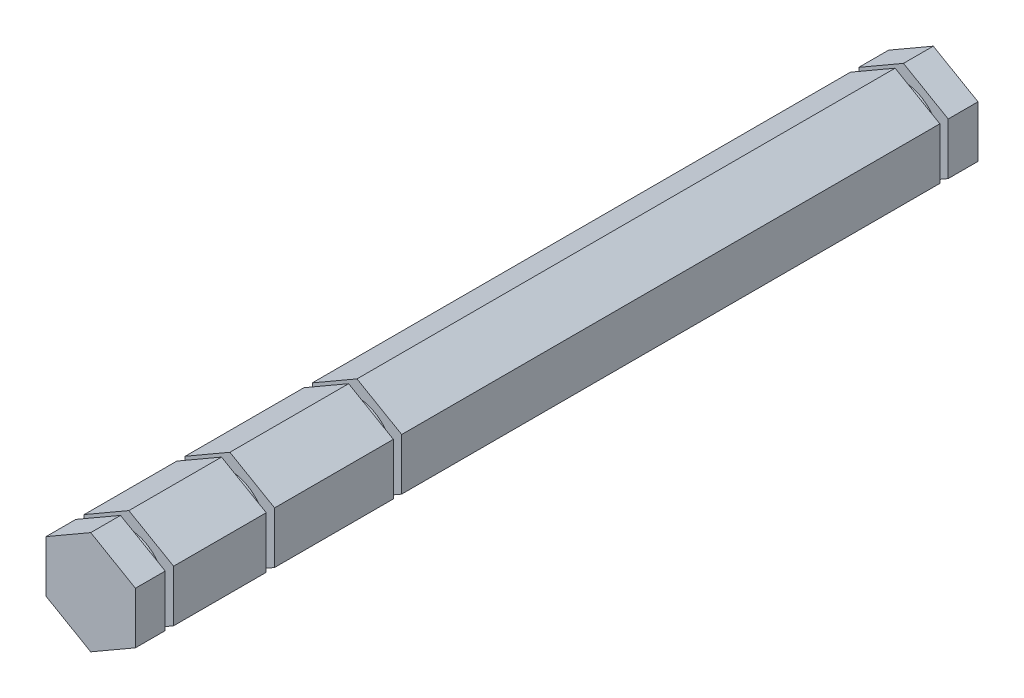
from build123d import *

# Parameters (mm, degrees)
BOSS_EXTRUDE1_DEPTH = 97.3582
SKETCH5_W           = 11.10345239
SKETCH5_H           = 12.145052052
SKETCH5_R           = 3.8481
CUT_EXTRUDE2_DEPTH  = 0.4445
SKETCH6_W           = 10.752068687
SKETCH6_H           = 11.509710708
SKETCH6_R           = 3.8481
CUT_EXTRUDE3_DEPTH  = 0.4445
SKETCH7_W           = 11.973800556
SKETCH7_H           = 12.349285591
SKETCH7_R           = 3.8481
CUT_EXTRUDE4_DEPTH  = 0.4445
SKETCH8_W           = 12.812601238
SKETCH8_H           = 11.483340014
SKETCH8_R           = 3.8481
CUT_EXTRUDE5_DEPTH  = 0.4445
SKETCH9_W           = 15.274592148
SKETCH9_H           = 13.977564657
CUT_EXTRUDE6_DEPTH  = 3.683
SKETCH11_W          = 19.244818326
SKETCH11_H          = 17.400851683
CUT_EXTRUDE7_DEPTH  = 3.937


with BuildPart() as part:
    # Sketch1 → Boss-Extrude1 (new body)
    with BuildSketch(Plane.XY):
        Polygon((0, 5.499261314), (-4.7625, 2.749630657), (-4.7625, -2.749630657), (0, -5.499261314), (4.7625, -2.749630657), (4.7625, 2.749630657), align=None)
    extrude(amount=BOSS_EXTRUDE1_DEPTH)

    # Sketch5 → Cut-Extrude2 (cut, symmetric)
    with BuildSketch(Plane.XY.offset(79.0448)):
        with Locations((-0.378227241, -0.09440181)):
            Rectangle(SKETCH5_W, SKETCH5_H)
        Circle(SKETCH5_R, mode=Mode.SUBTRACT)
    extrude(amount=CUT_EXTRUDE2_DEPTH, both=True, mode=Mode.SUBTRACT)

    # Sketch6 → Cut-Extrude3 (cut, symmetric)
    with BuildSketch(Plane.XY.offset(65.5066)):
        with Locations((-0.265980709, -0.185380495)):
            Rectangle(SKETCH6_W, SKETCH6_H)
        Circle(SKETCH6_R, mode=Mode.SUBTRACT)
    extrude(amount=CUT_EXTRUDE3_DEPTH, both=True, mode=Mode.SUBTRACT)

    # Sketch7 → Cut-Extrude4 (cut, symmetric)
    with BuildSketch(Plane.XY.offset(89.8017)):
        with Locations((-0.368386295, 0.291901412)):
            Rectangle(SKETCH7_W, SKETCH7_H)
        Circle(SKETCH7_R, mode=Mode.SUBTRACT)
    extrude(amount=CUT_EXTRUDE4_DEPTH, both=True, mode=Mode.SUBTRACT)

    # Sketch8 → Cut-Extrude5 (cut, symmetric)
    with BuildSketch(Plane(origin=(0, 0, 7.3025), x_dir=(-1, 0, 0), z_dir=(0, 0, -1))):
        with Locations((-0.353342966, -0.03551845)):
            Rectangle(SKETCH8_W, SKETCH8_H)
        Circle(SKETCH8_R, mode=Mode.SUBTRACT)
    extrude(amount=CUT_EXTRUDE5_DEPTH, both=True, mode=Mode.SUBTRACT)

    # Sketch9 → Cut-Extrude6 (cut)
    with BuildSketch(Plane(origin=(0, 0, 0), x_dir=(-1, 0, 0), z_dir=(0, 0, -1))):
        with Locations((0.659891111, -0.649631618)):
            Rectangle(SKETCH9_W, SKETCH9_H)
    extrude(amount=-CUT_EXTRUDE6_DEPTH, mode=Mode.SUBTRACT)

    # Sketch11 → Cut-Extrude7 (cut)
    with BuildSketch(Plane.XY.offset(97.3582)):
        with Locations((0.649471759, -1.230390771)):
            Rectangle(SKETCH11_W, SKETCH11_H)
    extrude(amount=-CUT_EXTRUDE7_DEPTH, mode=Mode.SUBTRACT)


solid = part.part
